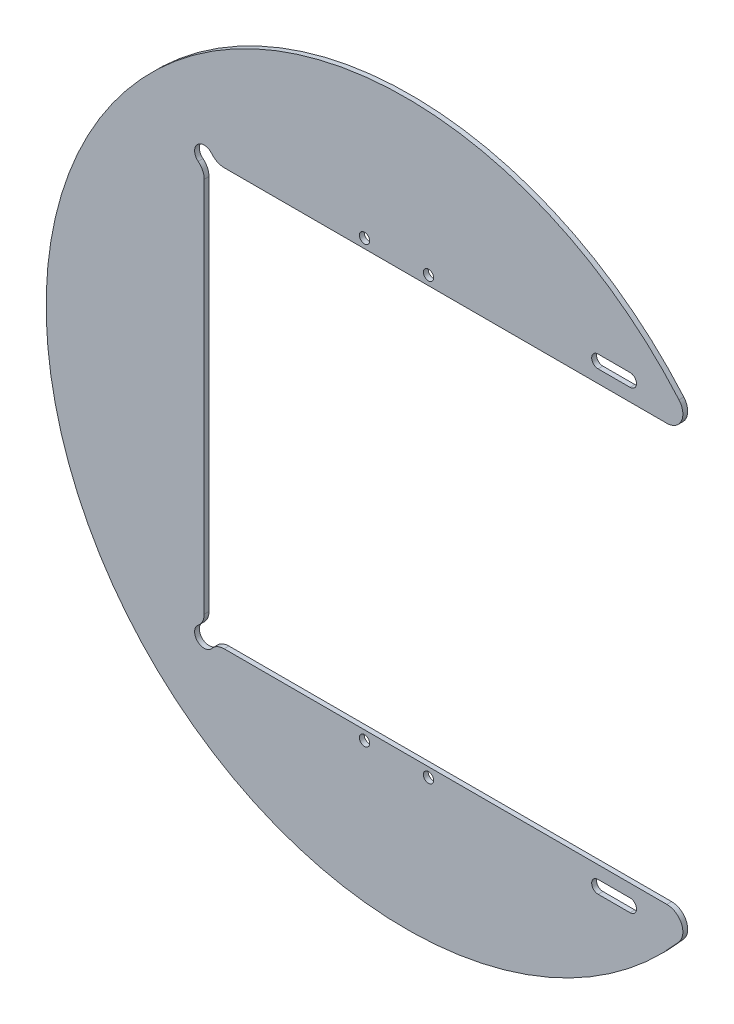
from build123d import *

# Parameters (mm, degrees)
SKETCH_1_R          = 112.5
EXTRUDE_1_DEPTH     = 1.5
SKETCH_2_R          = 1.6
SKETCH_2_W          = 175.6
SKETCH_2_H          = 130.2
CUT_EXTRUDE_1_DEPTH = 10
FILLET_1_R          = 5
SKETCH_3_R          = 3
CUT_EXTRUDE_2_DEPTH = 10
FILLET_2_R          = 5
CUT_EXTRUDE_3_DEPTH = 10


with BuildPart() as part:
    # 草图1 → 凸台-拉伸1 (new body)
    with BuildSketch(Plane.XY):
        Circle(SKETCH_1_R)
    extrude(amount=EXTRUDE_1_DEPTH)

    # 草图2 → 切除-拉伸1 (cut)
    with BuildSketch(Plane.XY.offset(1.5)):
        with Locations((-13, 68)):
            Circle(SKETCH_2_R)
        with Locations((7, 68)):
            Circle(SKETCH_2_R)
        with Locations((-13, -68)):
            Circle(SKETCH_2_R)
        with Locations((7, -68)):
            Circle(SKETCH_2_R)
        with Locations((24.7, 0)):
            Rectangle(SKETCH_2_W, SKETCH_2_H)
    extrude(amount=-CUT_EXTRUDE_1_DEPTH, mode=Mode.SUBTRACT)

    # 圆角1
    fillet_1_edges = [part.edges().sort_by_distance(p)[0] for p in [
        (91.750967297, 65.1, 0.75),
        (91.750967297, -65.1, 0.75),
    ]]
    fillet(fillet_1_edges, radius=FILLET_1_R)

    # 草图3 → 切除-拉伸2 (cut)
    with BuildSketch(Plane.XY.offset(1.5)):
        with Locations((-63.1, 65.1)):
            Circle(SKETCH_3_R)
        with Locations((-63.1, -65.1)):
            Circle(SKETCH_3_R)
    extrude(amount=-CUT_EXTRUDE_2_DEPTH, mode=Mode.SUBTRACT)

    # 圆角2
    fillet_2_edges = [part.edges().sort_by_distance(p)[0] for p in [
        (-60.1, -65.1, 0.75),
        (-60.1, 65.1, 0.75),
        (-63.1, 62.1, 0.75),
        (-63.1, -62.1, 0.75),
    ]]
    fillet(fillet_2_edges, radius=FILLET_2_R)

    # 草图4 → 切除-拉伸3 (cut)
    with BuildSketch(Plane.XY.offset(1.5)):
        with BuildLine():
            Line((60, 73.1), (70, 73.1))
            ThreePointArc((70, 73.1), (72, 71.1), (70, 69.1))
            Line((70, 69.1), (60, 69.1))
            ThreePointArc((60, 69.1), (58, 71.1), (60, 73.1))
        make_face()
        with BuildLine():
            Line((60, -69.1), (70, -69.1))
            ThreePointArc((70, -69.1), (72, -71.1), (70, -73.1))
            Line((70, -73.1), (60, -73.1))
            ThreePointArc((60, -73.1), (58, -71.1), (60, -69.1))
        make_face()
    extrude(amount=-CUT_EXTRUDE_3_DEPTH, mode=Mode.SUBTRACT)


solid = part.part
